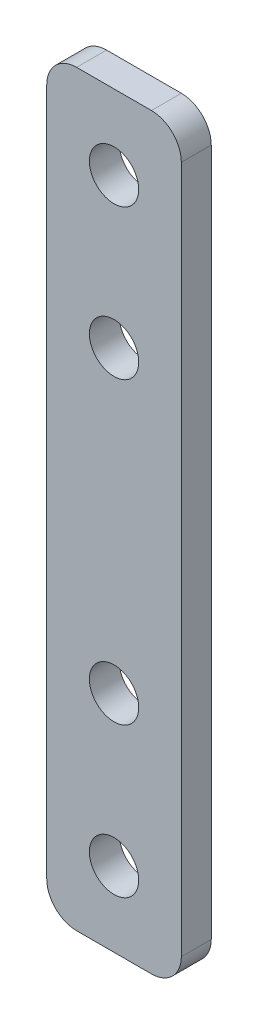
from build123d import *

# Parameters (mm, degrees)
SKETCH_1_W            = 9
SKETCH_1_H            = 50
EXTRUDE_1_DEPTH       = 2
HOLE_WIZARD_M41_D     = 3.3
HOLE_WIZARD_M41_DEPTH = 11.5
HOLE_WIZARD_M41_TIP   = 0.991420021
FILLET_1_R            = 2


with BuildPart() as part:
    # Эскиз1 → Бобышка-Вытянуть1 (new body)
    with BuildSketch(Plane.XY):
        Rectangle(SKETCH_1_W, SKETCH_1_H)
    extrude(amount=EXTRUDE_1_DEPTH)

    # Отверстие обработанное метчиком M41
    with Locations(Plane.XY.offset(2)):
        with Locations((0, -10), (0, 20), (0, 10), (0, -20)):
            Hole(HOLE_WIZARD_M41_D / 2, depth=HOLE_WIZARD_M41_DEPTH)
            with Locations((0, 0, -(HOLE_WIZARD_M41_DEPTH + HOLE_WIZARD_M41_TIP / 2))):  # 118° drill point
                Cone(0, HOLE_WIZARD_M41_D / 2, HOLE_WIZARD_M41_TIP, mode=Mode.SUBTRACT)

    # Скругление1
    fillet_1_edges = [part.edges().sort_by_distance(p)[0] for p in [
        (4.5, -25, 1),
        (-4.5, -25, 1),
        (-4.5, 25, 1),
        (4.5, 25, 1),
    ]]
    fillet(fillet_1_edges, radius=FILLET_1_R)


solid = part.part
